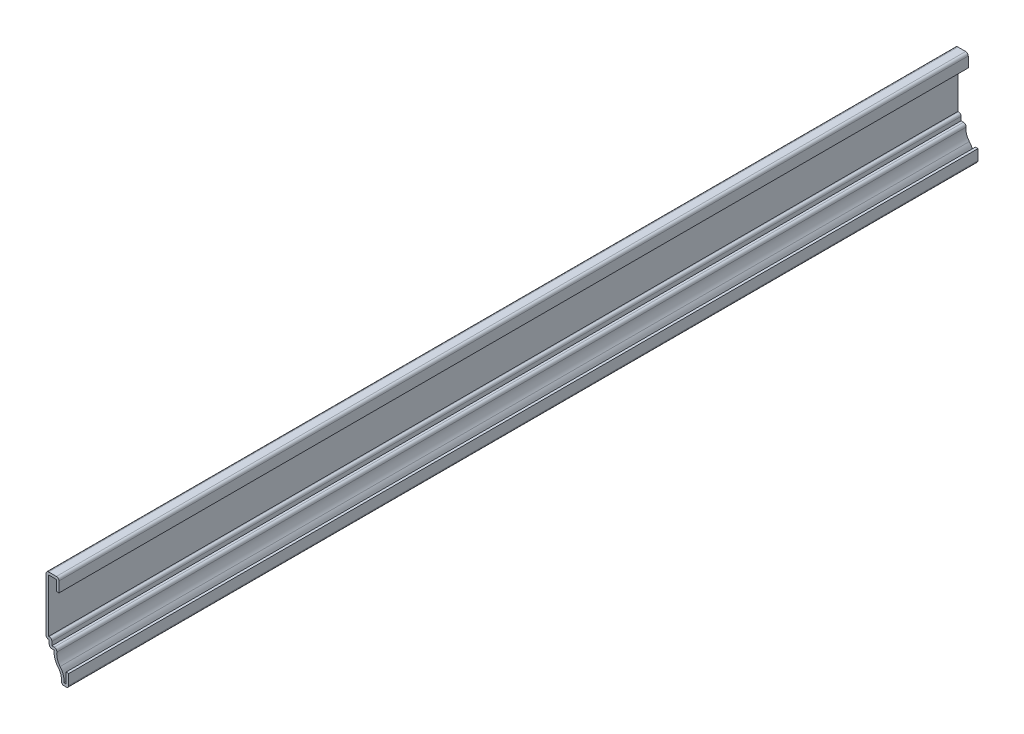
from build123d import *

# Parameters (mm, degrees)
EXTRUDE_THIN1_DEPTH = 444.5
FILLET1_R           = 1.27


with BuildPart() as part:
    # Sketch1 → Extrude-Thin1 (new body)
    with BuildSketch(Plane.XY):
        with BuildLine():
            Line((0, 6.35), (0, 0))
            Line((0, 0), (-3.96875, 0))
            ThreePointArc((-3.96875, 0), (-3.690796903, 3.353029057), (-5.164974256, 6.37740716))
            ThreePointArc((-5.164974256, 6.37740716), (-6.806228989, 9.331186698), (-7.070099394, 12.7))
            Line((-7.070099394, 12.7), (-9.525, 12.7))
            Line((-9.525, 12.7), (-9.525, 15.875))
            Line((-9.525, 15.875), (-11.1125, 15.875))
            Line((-11.1125, 15.875), (-11.1125, 44.45))
            Line((-11.1125, 44.45), (-4.7625, 44.45))
            Line((-4.7625, 44.45), (-4.7625, 38.1))
            Line((-4.7625, 38.1), (-6.0325, 38.1))
            Line((-6.0325, 38.1), (-6.0325, 43.18))
            Line((-6.0325, 43.18), (-9.8425, 43.18))
            Line((-9.8425, 43.18), (-9.8425, 17.145))
            Line((-9.8425, 17.145), (-8.255, 17.145))
            Line((-8.255, 17.145), (-8.255, 13.97))
            Line((-8.255, 13.97), (-5.446343041, 13.97))
            ThreePointArc((-5.446343041, 13.97), (-5.765030298, 10.42206557), (-4.211578375, 7.216416274))
            ThreePointArc((-4.211578375, 7.216416274), (-2.654146129, 4.440218432), (-2.366770495, 1.27))
            Line((-2.366770495, 1.27), (-1.27, 1.27))
            Line((-1.27, 1.27), (-1.27, 6.35))
            Line((-1.27, 6.35), (0, 6.35))
        make_face()
    extrude(amount=-EXTRUDE_THIN1_DEPTH)

    # Fillet1
    fillet1_edges = [part.edges().sort_by_distance(p)[0] for p in [
        (-8.255, 17.145, -222.25),
        (-5.446343041, 13.97, -222.25),
        (0, 0, -222.25),
        (-3.96875, 0, -222.25),
        (-9.525, 12.7, -222.25),
        (-11.1125, 15.875, -222.25),
        (-11.1125, 44.45, -222.25),
        (-4.7625, 44.45, -222.25),
    ]]
    fillet(fillet1_edges, radius=FILLET1_R)


solid = part.part
